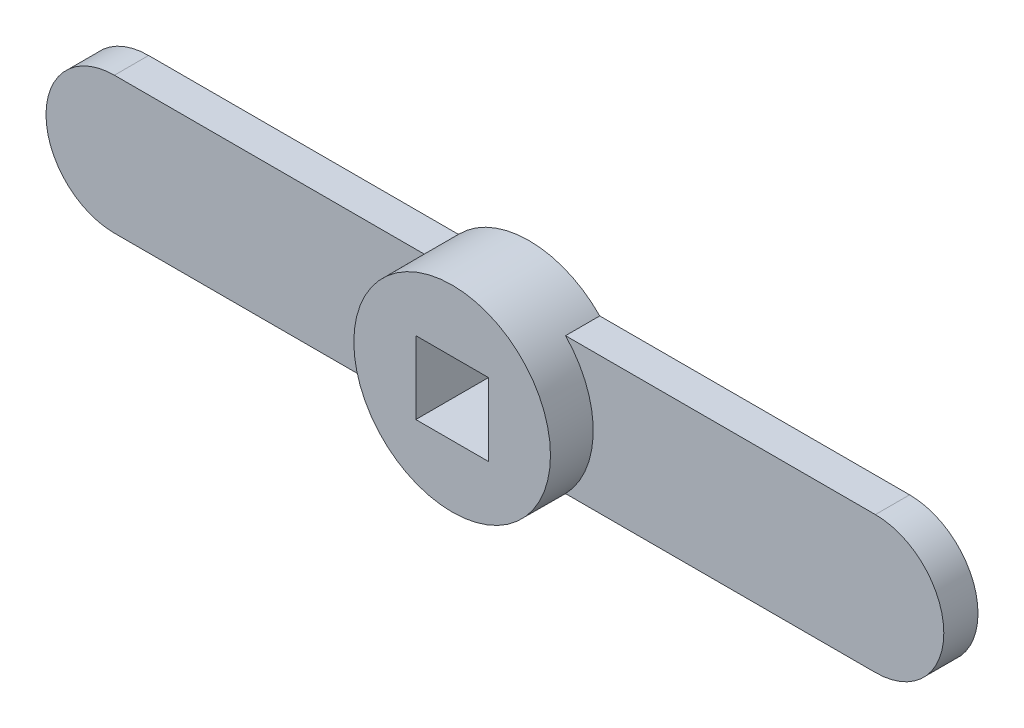
from build123d import *

# Parameters (mm, degrees)
EXTRUDE_1_DEPTH     = 4
SKETCH_2_R          = 11.5
EXTRUDE_2_DEPTH     = 9
SKETCH_3_W          = 8.5
SKETCH_3_H          = 8.5
CUT_EXTRUDE_1_DEPTH = 10


with BuildPart() as part:
    # Эскиз1 → Бобышка-Вытянуть1 (new body)
    with BuildSketch(Plane.XY):
        with BuildLine():
            Line((-44.5, 8), (44.5, 8))
            ThreePointArc((44.5, 8), (52.5, 0), (44.5, -8))
            Line((44.5, -8), (-44.5, -8))
            ThreePointArc((-44.5, -8), (-52.5, 0), (-44.5, 8))
        make_face()
    extrude(amount=EXTRUDE_1_DEPTH)

    # Эскиз2 → Бобышка-Вытянуть2 (add)
    with BuildSketch(Plane(origin=(0, 0, 0), x_dir=(-1, 0, 0), z_dir=(0, 0, -1))):
        Circle(SKETCH_2_R)
    extrude(amount=-EXTRUDE_2_DEPTH)

    # Эскиз3 → Вырез-Вытянуть1 (cut, through all)
    with BuildSketch(Plane(origin=(0, 0, 0), x_dir=(-1, 0, 0), z_dir=(0, 0, -1))):
        Rectangle(SKETCH_3_W, SKETCH_3_H)
    extrude(amount=-CUT_EXTRUDE_1_DEPTH, mode=Mode.SUBTRACT)


solid = part.part
